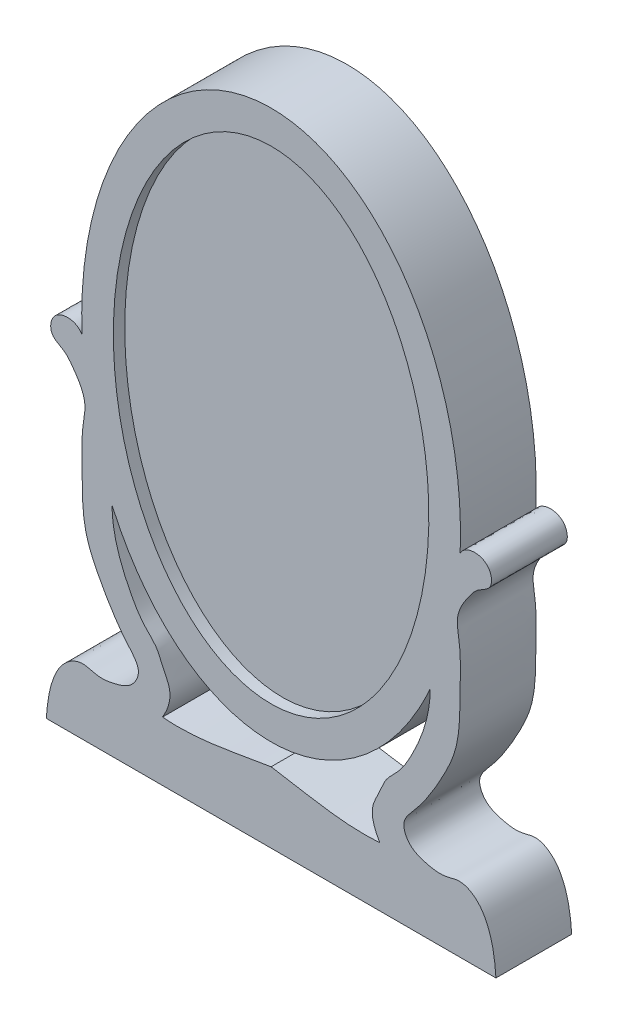
from build123d import *

# Parameters (mm, degrees)
SKETCH1_RX                = 18.406767119
SKETCH1_RY                = 12.7
SKETCH1_RX_2              = 16.195564575
SKETCH1_RY_2              = 10.57791487
BOSS_EXTRUDE1_DEPTH       = 5.08
SKETCH3_RX                = 16.195564575
SKETCH3_RY                = 10.57791487
BOSS_EXTRUDE2_DEPTH       = 5.08
SKETCH6_RX                = 16.195564575
SKETCH6_RY                = 10.57791487
CUT_EXTRUDE1_DEPTH        = 0.762
F_8_32_TAPPED_HOLE1_D     = 3.4544
F_8_32_TAPPED_HOLE1_DEPTH = 2.54
F_8_32_TAPPED_HOLE1_TIP   = 1.037806461


with BuildPart() as part:
    # Sketch1 → Boss-Extrude1 (new body)
    with BuildSketch(Plane.XY):
        with Locations(Location((0, 0), (0, 0, 90))):
            Ellipse(SKETCH1_RX, SKETCH1_RY)
        with Locations(Location((0, 0), (0, 0, 90))):
            Ellipse(SKETCH1_RX_2, SKETCH1_RY_2, mode=Mode.SUBTRACT)
    extrude(amount=BOSS_EXTRUDE1_DEPTH)

    # Sketch3 → Boss-Extrude2 (add)
    with BuildSketch(Plane.XY):
        with Locations(Location((0, 0), (0, 0, 90))):
            Ellipse(SKETCH3_RX, SKETCH3_RY)
        with BuildLine():
            add(Edge.make_bspline(
                [(-12.677109266, -1.104650076), (-13.014729574, -0.444657082), (-14.686418271, -0.376477607), (-14.90108116, -2.203498744), (-13.846872785, -2.553594812), (-13.106687343, -3.528477034), (-12.321773847, -4.722284306), (-12.593267812, -6.061264169), (-12.722979981, -7.354834662), (-12.635517712, -9.535807011), (-12.715310227, -12.133811763), (-11.552062113, -14.641557308), (-10.592371538, -16.288882304), (-9.607983342, -17.599787289), (-8.66931519, -18.5874043), (-9.254836928, -19.882387813), (-10.403303402, -20.283647806), (-11.586651289, -20.481236013), (-12.674454091, -20.017494126), (-13.950510554, -20.648393491), (-14.836745379, -22.290205983), (-15.018180684, -23.717279245), (-15.073740621, -24.575146101)],
                knots=[0, 0, 0, 0, 0.066937012, 0.100724069, 0.132254973, 0.158396111, 0.217811023, 0.25791935, 0.283383059, 0.341891746, 0.465467037, 0.523432421, 0.602213692, 0.644587561, 0.683892573, 0.717443219, 0.758396822, 0.795190358, 0.829586576, 0.86376833, 0.918491893, 1, 1, 1, 1], degree=3))
            Line((-15.073740621, -24.575146101), (15.073740621, -24.575146101))
            add(Edge.make_bspline(
                [(12.677109266, -1.104650076), (13.014729574, -0.444657082), (14.686418271, -0.376477607), (14.90108116, -2.203498744), (13.846872785, -2.553594812), (13.106687343, -3.528477034), (12.321773847, -4.722284306), (12.593267812, -6.061264169), (12.722979981, -7.354834662), (12.635517712, -9.535807011), (12.715310227, -12.133811763), (11.552062113, -14.641557308), (10.592371538, -16.288882304), (9.607983342, -17.599787289), (8.66931519, -18.5874043), (9.254836928, -19.882387813), (10.403303402, -20.283647806), (11.586651289, -20.481236013), (12.674454091, -20.017494126), (13.950510554, -20.648393491), (14.836745379, -22.290205983), (15.018180684, -23.717279245), (15.073740621, -24.575146101)],
                knots=[0, 0, 0, 0, 0.066937012, 0.100724069, 0.132254973, 0.158396111, 0.217811023, 0.25791935, 0.283383059, 0.341891746, 0.465467037, 0.523432421, 0.602213692, 0.644587561, 0.683892573, 0.717443219, 0.758396822, 0.795190358, 0.829586576, 0.86376833, 0.918491893, 1, 1, 1, 1], degree=3))
            add(Edge.make_bspline(
                [(10.66914755, -9.984686138), (12.477088722, -5.926544581), (12.677109266, -1.104650076)],
                knots=[4.13904243, 4.13904243, 4.13904243, 4.652339639, 4.652339639, 4.652339639], degree=2, weights=[1, 0.967246128, 1]))
            add(Edge.make_bspline(
                [(7.282383953, -20.602656668), (6.983422778, -20.109825748), (6.51747466, -18.976948289), (7.260733908, -17.780827699), (7.640071124, -16.678822101), (8.662516285, -15.817219187), (9.953384312, -13.601158486), (10.659574708, -11.575789329), (10.66914755, -9.984686138)],
                knots=[0, 0, 0, 0, 0.156869423, 0.269880163, 0.345336763, 0.453457095, 0.602334664, 1, 1, 1, 1], degree=3))
            add(Edge.make_bspline(
                [(0, -19.846510228), (2.413240871, -20.216104174), (4.822486462, -20.817195509), (7.282383953, -20.602656668)],
                knots=[0, 0, 0, 0, 1, 1, 1, 1], degree=3))
            add(Edge.make_bspline(
                [(0, -19.846510228), (-2.413240871, -20.216104174), (-4.822486462, -20.817195509), (-7.282383953, -20.602656668)],
                knots=[0, 0, 0, 0, 1, 1, 1, 1], degree=3))
            add(Edge.make_bspline(
                [(-7.282383953, -20.602656668), (-6.983422778, -20.109825748), (-6.51747466, -18.976948289), (-7.260733908, -17.780827699), (-7.640071124, -16.678822101), (-8.662516285, -15.817219187), (-9.953384312, -13.601158486), (-10.659574708, -11.575789329), (-10.66914755, -9.984686138)],
                knots=[0, 0, 0, 0, 0.156869423, 0.269880163, 0.345336763, 0.453457095, 0.602334664, 1, 1, 1, 1], degree=3))
            add(Edge.make_bspline(
                [(-12.677109266, -1.104650076), (-12.477088722, -5.926544581), (-10.66914755, -9.984686138)],
                knots=[1.630845668, 1.630845668, 1.630845668, 2.144142877, 2.144142877, 2.144142877], degree=2, weights=[1, 0.967246128, 1]))
        make_face()
    extrude(amount=BOSS_EXTRUDE2_DEPTH)

    # Sketch6 → Cut-Extrude1 (cut)
    with BuildSketch(Plane.XY.offset(5.08)):
        with Locations(Location((0, 0), (0, 0, 90))):
            Ellipse(SKETCH6_RX, SKETCH6_RY)
    extrude(amount=-CUT_EXTRUDE1_DEPTH, mode=Mode.SUBTRACT)

    # #8-32 Tapped Hole1
    with Locations(Plane.XZ.offset(24.575146101)):
        with Locations((0, 2.54)):
            Hole(F_8_32_TAPPED_HOLE1_D / 2, depth=F_8_32_TAPPED_HOLE1_DEPTH)
            with Locations((0, 0, -(F_8_32_TAPPED_HOLE1_DEPTH + F_8_32_TAPPED_HOLE1_TIP / 2))):  # 118° drill point
                Cone(0, F_8_32_TAPPED_HOLE1_D / 2, F_8_32_TAPPED_HOLE1_TIP, mode=Mode.SUBTRACT)


solid = part.part
